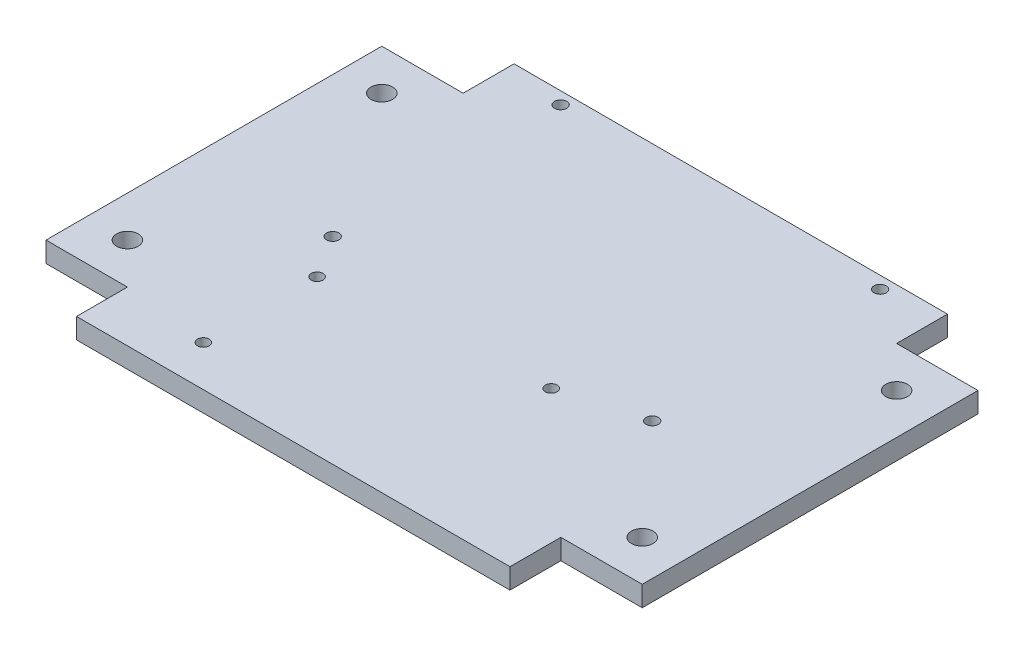
from build123d import *

# Parameters (mm, degrees)
SALIENTE_EXTRUIR1_DEPTH = 5
CROQUIS2_R              = 2.65
CORTAR_EXTRUIR1_DEPTH   = 5
CROQUIS5_R              = 1.5
CROQUIS5_R_2            = 1.445
CORTAR_EXTRUIR2_DEPTH   = 10


with BuildPart() as part:
    # Croquis1 → Saliente-Extruir1 (new body)
    with BuildSketch(Plane(origin=(0, 0, 0), x_dir=(1, 0, 0), z_dir=(0, 1, 0))):
        Polygon((53.25, -50), (53.25, -37.5), (73.25, -37.5), (73.25, 45), (53.25, 45), (53.25, 57.5), (-53.25, 57.5), (-53.25, 45), (-73.25, 45), (-73.25, -37.5), (-53.25, -37.5), (-53.25, -50), align=None)
    extrude(amount=SALIENTE_EXTRUIR1_DEPTH)

    # Croquis2 → Cortar-Extruir1 (cut)
    with BuildSketch(Plane(origin=(0, 5, 0), x_dir=(1, 0, 0), z_dir=(0, 1, 0))):
        with Locations((-63.25, 35)):
            Circle(CROQUIS2_R)
        with Locations((-63.25, -27.5)):
            Circle(CROQUIS2_R)
        with Locations((63.25, 35)):
            Circle(CROQUIS2_R)
        with Locations((63.25, -27.5)):
            Circle(CROQUIS2_R)
    extrude(amount=-CORTAR_EXTRUIR1_DEPTH, mode=Mode.SUBTRACT)

    # Croquis5 → Cortar-Extruir2 (cut)
    with BuildSketch(Plane(origin=(0, 5, 0), x_dir=(1, 0, 0), z_dir=(0, 1, 0))):
        with Locations((-38.797689263, 54.5)):
            Circle(CROQUIS5_R)
        with Locations((39.702310737, 54.5)):
            Circle(CROQUIS5_R)
        with Locations((-38.797689263, -1.5)):
            Circle(CROQUIS5_R)
        with Locations((39.702310737, -1.5)):
            Circle(CROQUIS5_R)
        with Locations((-32.131872623, -39.96)):
            Circle(CROQUIS5_R_2)
        with Locations((-32.131872623, -12)):
            Circle(CROQUIS5_R_2)
        with Locations((20.388127377, -7)):
            Circle(CROQUIS5_R_2)
    extrude(amount=-CORTAR_EXTRUIR2_DEPTH, mode=Mode.SUBTRACT)


solid = part.part
